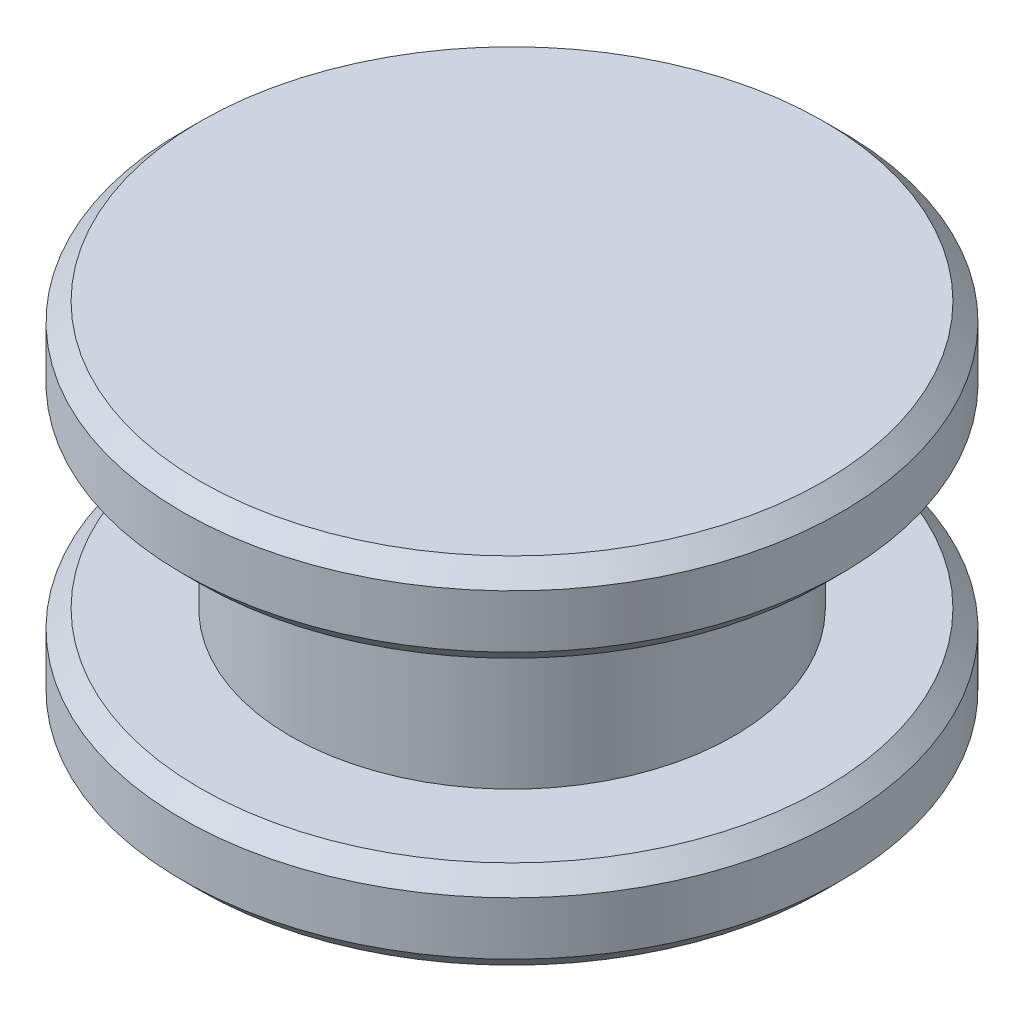
from build123d import *

# Parameters (mm, degrees)
SKETCH2_R           = 0.25
BOSS_EXTRUDE1_DEPTH = 0.2
SKETCH3_R           = 0.371871199
BOSS_EXTRUDE2_DEPTH = 0.1
SKETCH4_R           = 0.371871199
BOSS_EXTRUDE3_DEPTH = 0.1
CHAMFER1_SIZE       = 0.02
CHAMFER2_SIZE       = 0.02
CHAMFER3_SIZE       = 0.02


with BuildPart() as part:
    # Sketch2 → Boss-Extrude1 (new body)
    with BuildSketch(Plane(origin=(0, 0, 0), x_dir=(1, 0, 0), z_dir=(0, 1, 0))):
        Circle(SKETCH2_R)
    extrude(amount=BOSS_EXTRUDE1_DEPTH)

    # Sketch3 → Boss-Extrude2 (add)
    with BuildSketch(Plane(origin=(0, 0.2, 0), x_dir=(1, 0, 0), z_dir=(0, 1, 0))):
        Circle(SKETCH3_R)
    extrude(amount=BOSS_EXTRUDE2_DEPTH)

    # Sketch4 → Boss-Extrude3 (add)
    with BuildSketch(Plane.XZ):
        Circle(SKETCH4_R)
    extrude(amount=BOSS_EXTRUDE3_DEPTH)

    # Chamfer1
    chamfer1_edges = [part.edges().sort_by_distance(p)[0] for p in [
        (-0.371871199, 0.3, 0),
    ]]
    chamfer(chamfer1_edges, length=CHAMFER1_SIZE)

    # Chamfer2
    chamfer2_edges = [part.edges().sort_by_distance(p)[0] for p in [
        (-0.371871199, 0.2, 0),
        (-0.371871199, 0, 0),
    ]]
    chamfer(chamfer2_edges, length=CHAMFER2_SIZE)

    # Chamfer3
    chamfer3_edges = [part.edges().sort_by_distance(p)[0] for p in [
        (-0.371871199, -0.1, 0),
    ]]
    chamfer(chamfer3_edges, length=CHAMFER3_SIZE)


solid = part.part
